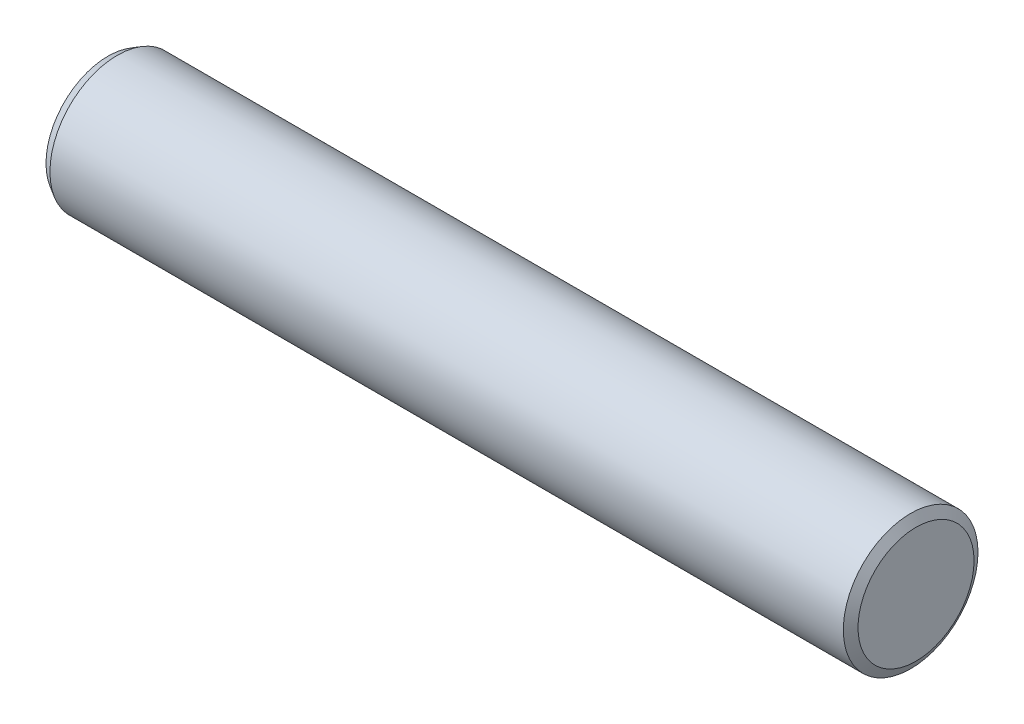
from build123d import *

# Parameters (mm, degrees)
SKETCH1_W             = 30
SKETCH1_H             = 2.5
CHAMFER1_SIZE         = 0.2
CHAMFER1_SIZE2        = 0.346410162
CHAMFER1_PART_2_SIZE  = 0.2
CHAMFER1_PART_2_SIZE2 = 0.346410162


with BuildPart() as part:
    # Sketch1 → Revolve1 (revolve)
    with BuildSketch(Plane.XY):
        with Locations((-15, 1.25)):
            Rectangle(SKETCH1_W, SKETCH1_H)
    revolve(axis=Axis((0, 0, 0), (-1, 0, 0)))

    # Chamfer1
    chamfer1_edges = [part.edges().sort_by_distance(p)[0] for p in [
        (-30, -2.5, 0),
    ]]
    chamfer1_side = [part.faces().sort_by_distance(p)[0] for p in [
        (-30, 0, 0),
    ]]
    chamfer(chamfer1_edges, length=CHAMFER1_SIZE, length2=CHAMFER1_SIZE2, reference=chamfer1_side[0])

    # Chamfer1 part 2
    chamfer1_part_2_edges = [part.edges().sort_by_distance(p)[0] for p in [
        (0, -2.5, 0),
    ]]
    chamfer1_part_2_side = [part.faces().sort_by_distance(p)[0] for p in [
        (-15, -2.5, 0),
    ]]
    chamfer(chamfer1_part_2_edges, length=CHAMFER1_PART_2_SIZE, length2=CHAMFER1_PART_2_SIZE2, reference=chamfer1_part_2_side[0])


solid = part.part
